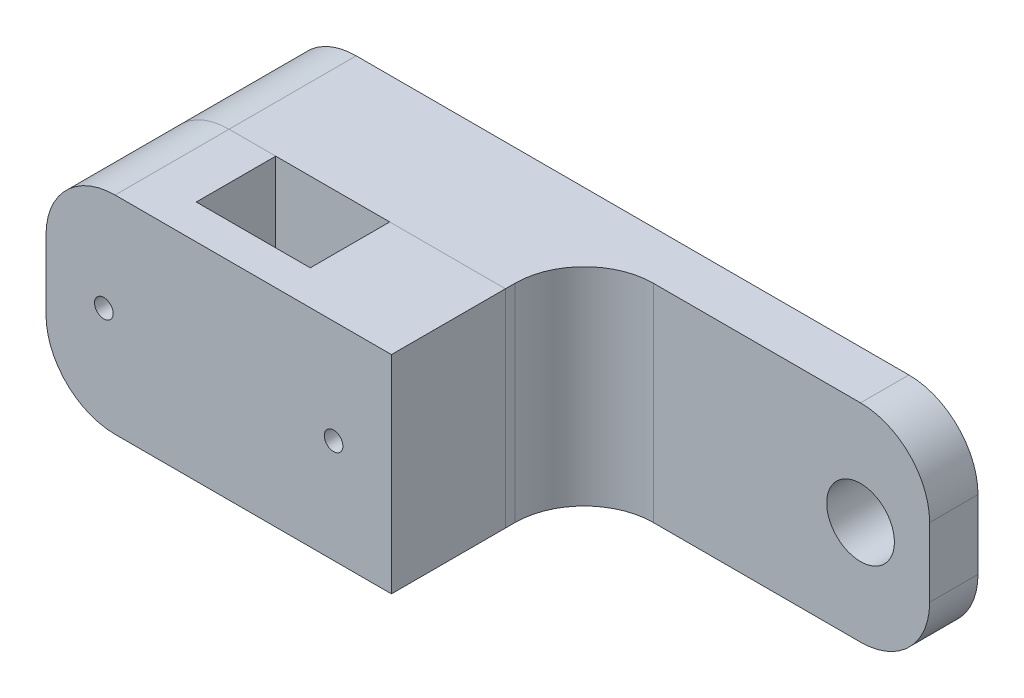
from build123d import *

# Parameters (mm, degrees)
SKETCH1_W             = 50
SKETCH1_H             = 30
BOSS_EXTRUDE1_DEPTH   = 18.4
SKETCH1_3_W           = 50
SKETCH1_3_H           = 30
SKETCH1_3_R           = 4.9
BOSS_EXTRUDE2_DEPTH   = 7
SKETCH2_R             = 1.35
CUT_EXTRUDE1_DEPTH    = 27
SKETCH2_3_W           = 16.75
SKETCH2_3_H           = 30
SKETCH2_3_R           = 1.35
BOSS_EXTRUDE3_DEPTH   = 11.5
BOSS_EXTRUDE3_2_DEPTH = 11.5
BOSS_EXTRUDE4_START   = 5
SKETCH3_W             = 50
SKETCH3_H             = 30
SKETCH3_R             = 1.35
BOSS_EXTRUDE4_DEPTH   = 5
FILLET1_R             = 10
FILLET2_R             = 10


with BuildPart() as part:
    # Sketch1 → Boss-Extrude1 (new body)
    with BuildSketch(Plane.XY):
        with Locations((25, 15)):
            Rectangle(SKETCH1_W, SKETCH1_H)
    extrude(amount=BOSS_EXTRUDE1_DEPTH)

    # Sketch1_3 → Boss-Extrude2 (add)
    with BuildSketch(Plane.XY):
        with Locations((75, 15)):
            Rectangle(SKETCH1_3_W, SKETCH1_3_H)
        with Locations((90, 15)):
            Circle(SKETCH1_3_R, mode=Mode.SUBTRACT)
    extrude(amount=BOSS_EXTRUDE2_DEPTH)

    # Sketch2 → Cut-Extrude1 (cut)
    with BuildSketch(Plane.XY.offset(18.4)):
        with Locations((8.375, 15)):
            Circle(SKETCH2_R)
        with Locations((41.625, 15)):
            Circle(SKETCH2_R)
    extrude(amount=-CUT_EXTRUDE1_DEPTH, mode=Mode.SUBTRACT)

    # Fillet1
    fillet1_edges = [part.edges().sort_by_distance(p)[0] for p in [
        (0, 30, 9.2),
        (0, 0, 9.2),
        (100, 30, 3.5),
        (100, 0, 3.5),
        (50, 15, 7),
    ]]
    fillet(fillet1_edges, radius=FILLET1_R)


with BuildPart() as body_2:
    # Sketch2_3 → Boss-Extrude3 (new body)
    with BuildSketch(Plane.XY.offset(18.4)):
        with Locations((8.375, 15)):
            Rectangle(SKETCH2_3_W, SKETCH2_3_H)
        with Locations((8.375, 15)):
            Circle(SKETCH2_3_R, mode=Mode.SUBTRACT)
    extrude(amount=BOSS_EXTRUDE3_DEPTH)



with BuildPart() as body_3:
    # Sketch2_3 → Boss-Extrude3 2 (new body)
    with BuildSketch(Plane.XY.offset(18.4)):
        with Locations((41.625, 15)):
            Rectangle(SKETCH2_3_W, SKETCH2_3_H)
        with Locations((41.625, 15)):
            Circle(SKETCH2_3_R, mode=Mode.SUBTRACT)
    extrude(amount=BOSS_EXTRUDE3_2_DEPTH)


with BuildPart() as body_2_1:
    add(body_2.part)

    add(body_3.part)  # Boss-Extrude4 merges body 3
    # Sketch3 → Boss-Extrude4 (add)
    with BuildSketch(Plane.XY.offset(29.9).offset(BOSS_EXTRUDE4_START)):
        with Locations((25, 15)):
            Rectangle(SKETCH3_W, SKETCH3_H)
        with Locations((8.375, 15)):
            Circle(SKETCH3_R, mode=Mode.SUBTRACT)
        with Locations((41.625, 15)):
            Circle(SKETCH3_R, mode=Mode.SUBTRACT)
    extrude(amount=-BOSS_EXTRUDE4_DEPTH)

    # Fillet2
    fillet2_edges = [body_2_1.edges().sort_by_distance(p)[0] for p in [
        (0, 30, 26.65),
        (0, 0, 26.65),
    ]]
    fillet(fillet2_edges, radius=FILLET2_R)


solid = Compound([part.part, body_2_1.part])
